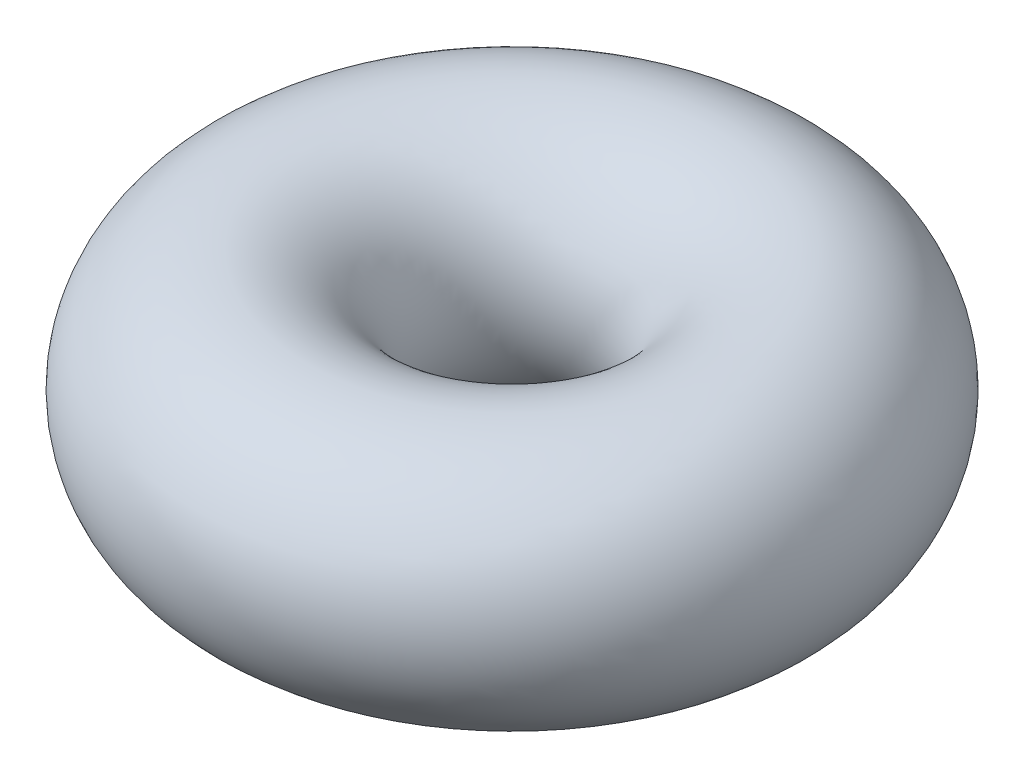
from build123d import *

# Parameters (mm, degrees)
SKETCH1_R = 2.375


with BuildPart() as part:
    # Sketch1 → Revolve1 (revolve)
    with BuildSketch(Plane.XY):
        with Locations((-4, 0)):
            Circle(SKETCH1_R)
    revolve(axis=Axis((0, 0, 0), (0, -1, 0)))


solid = part.part
